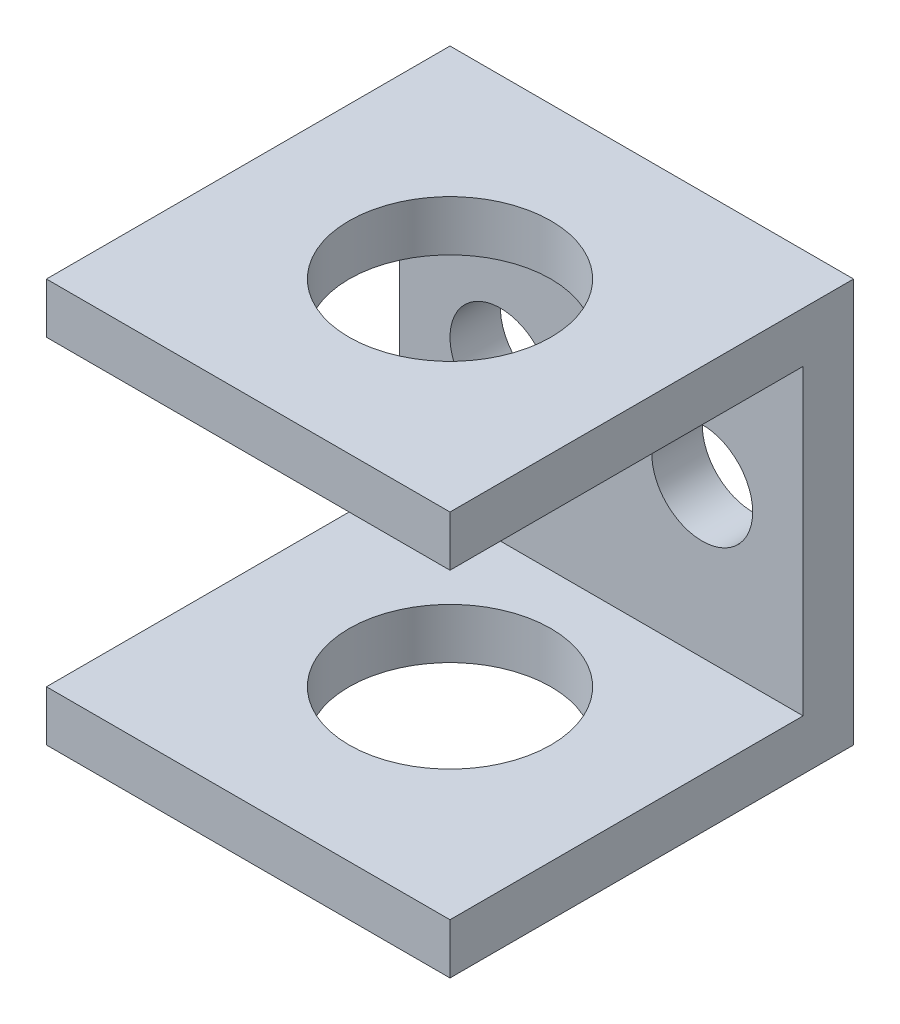
from build123d import *

# Parameters (mm, degrees)
SKETCH1_W           = 20
SKETCH1_H           = 20
BOSS_EXTRUDE1_DEPTH = 20
SKETCH2_W           = 20
SKETCH2_H           = 15
CUT_EXTRUDE1_DEPTH  = 17.5
SKETCH3_R           = 5
CUT_EXTRUDE2_DEPTH  = 21
SKETCH4_R           = 2.5
CUT_EXTRUDE3_DEPTH  = 3.5


with BuildPart() as part:
    # Sketch1 → Boss-Extrude1 (new body)
    with BuildSketch(Plane.XY):
        with Locations((10, 10)):
            Rectangle(SKETCH1_W, SKETCH1_H)
    extrude(amount=BOSS_EXTRUDE1_DEPTH)

    # Sketch2 → Cut-Extrude1 (cut)
    with BuildSketch(Plane.XY.offset(20)):
        with Locations((10, 10)):
            Rectangle(SKETCH2_W, SKETCH2_H)
    extrude(amount=-CUT_EXTRUDE1_DEPTH, mode=Mode.SUBTRACT)

    # Sketch3 → Cut-Extrude2 (cut, through all)
    with BuildSketch(Plane(origin=(0, 20, 0), x_dir=(1, 0, 0), z_dir=(0, 1, 0))):
        with Locations((10, -10)):
            Circle(SKETCH3_R)
    extrude(amount=-CUT_EXTRUDE2_DEPTH, mode=Mode.SUBTRACT)

    # Sketch4 → Cut-Extrude3 (cut, through all)
    with BuildSketch(Plane.XY.offset(2.5)):
        with Locations((15, 10)):
            Circle(SKETCH4_R)
        with Locations((5, 10)):
            Circle(SKETCH4_R)
    extrude(amount=-CUT_EXTRUDE3_DEPTH, mode=Mode.SUBTRACT)


solid = part.part
